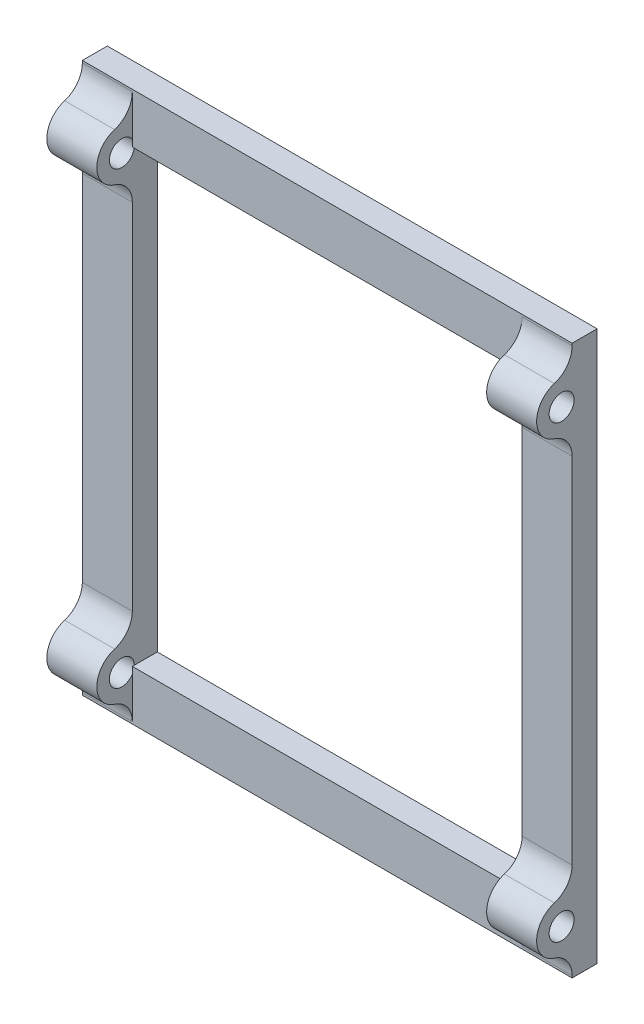
from build123d import *

# Parameters (mm, degrees)
ESQUISSE1_W                     = 98
ESQUISSE1_H                     = 110
ESQUISSE1_W_2                   = 78
ESQUISSE1_H_2                   = 90
BOSS_EXTRU_1_DEPTH              = 5
ESQUISSE2_R                     = 5
ESQUISSE2_R_2                   = 2.5
BOSS_EXTRU_2_DEPTH              = 10
ESQUISSE3_R                     = 2.5
ENL_V_MAT_EXTRU_1_DEPTH         = 10
R_P_TITION_LIN_AIRE3_COUNT      = 2
R_P_TITION_LIN_AIRE3_PITCH      = 88
R_P_TITION_LIN_AIRE3_COUNT_DIR2 = 2
R_P_TITION_LIN_AIRE3_PITCH_DIR2 = 90
CONG_1_R                        = 5


with BuildPart() as part:
    # Esquisse1 → Boss.-Extru.1 (new body)
    with BuildSketch(Plane.XY):
        with Locations((54.666666667, 49.166666667)):
            Rectangle(ESQUISSE1_W, ESQUISSE1_H)
        with Locations((54.666666667, 49.166666667)):
            Rectangle(ESQUISSE1_W_2, ESQUISSE1_H_2, mode=Mode.SUBTRACT)
    extrude(amount=BOSS_EXTRU_1_DEPTH)

    # Esquisse2 → Boss.-Extru.2 (add)
    with BuildSketch(Plane(origin=(103.666666667, 0, 0), x_dir=(0, 0, -1), z_dir=(1, 0, 0))):
        with Locations((-7.1, 94.166666667)):
            Circle(ESQUISSE2_R)
        with Locations((-7.1, 94.166666667)):
            Circle(ESQUISSE2_R_2, mode=Mode.SUBTRACT)
    boss_extru_2 = extrude(amount=-BOSS_EXTRU_2_DEPTH)

    # Esquisse3 → Enlèv. mat.-Extru.1 (cut)
    with BuildSketch(Plane(origin=(103.666666667, 0, 0), x_dir=(0, 0, -1), z_dir=(1, 0, 0))):
        with Locations((-7.1, 94.166666667)):
            Circle(ESQUISSE3_R)
    enl_v_mat_extru_1 = extrude(amount=-ENL_V_MAT_EXTRU_1_DEPTH, mode=Mode.SUBTRACT)

    # Répétition linéaire3: Boss.-Extru.2, Enl_v. mat.-Extru.1 2 × 2
    with Locations(*[(-i * R_P_TITION_LIN_AIRE3_PITCH, -j * R_P_TITION_LIN_AIRE3_PITCH_DIR2, 0) for i in range(R_P_TITION_LIN_AIRE3_COUNT) for j in range(R_P_TITION_LIN_AIRE3_COUNT_DIR2) if (i, j) != (0, 0)]):
        add(boss_extru_2)
        add(enl_v_mat_extru_1, mode=Mode.SUBTRACT)

    # Congé1
    cong_1_edges = [part.edges().sort_by_distance(p)[0] for p in [
        (10.666666667, -0.370953855, 5),
        (10.666666667, 8.704287188, 5),
        (98.666666667, 89.629046145, 5),
        (98.666666667, 98.704287188, 5),
        (98.666666667, -0.370953855, 5),
        (98.666666667, 8.704287188, 5),
        (10.666666667, 89.629046145, 5),
        (10.666666667, 98.704287188, 5),
    ]]
    fillet(cong_1_edges, radius=CONG_1_R)


solid = part.part
